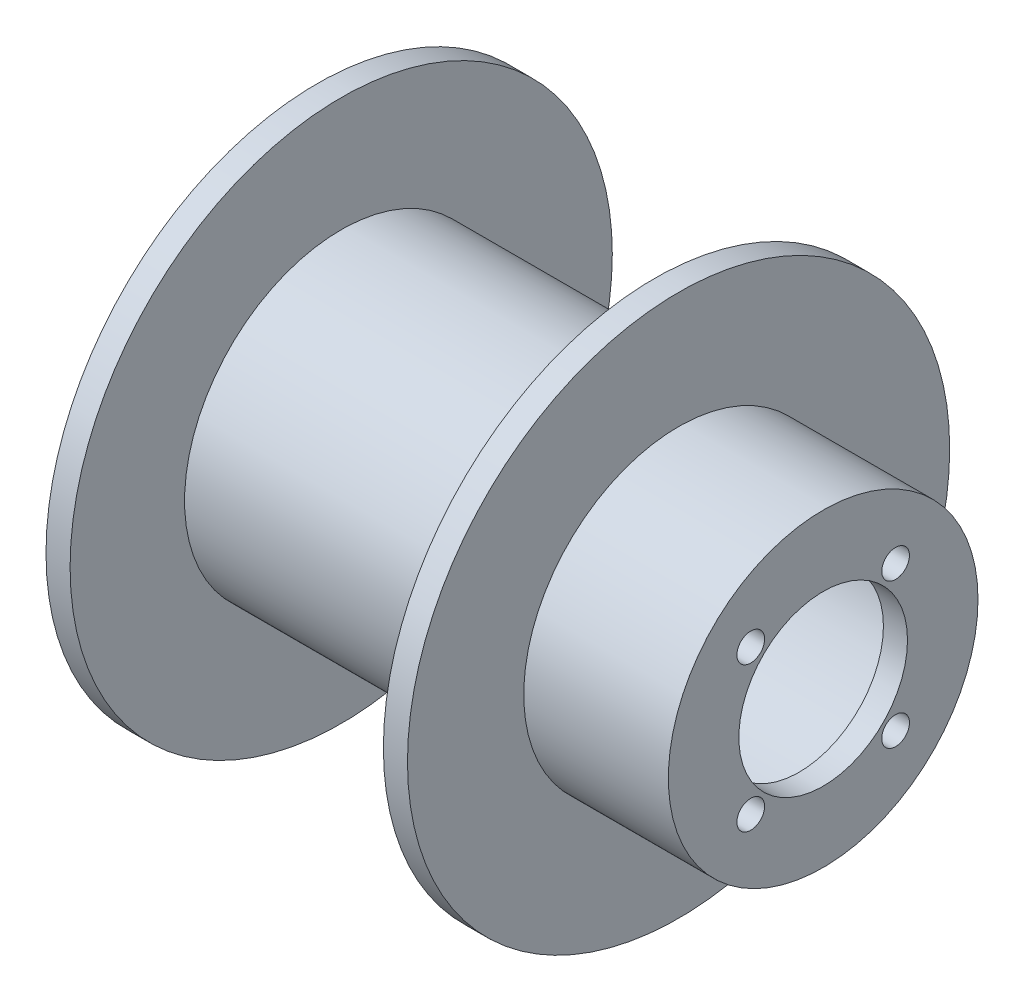
from build123d import *

# Parameters (mm, degrees)
SKETCH2_R           = 12.85
SKETCH2_R_2         = 12
BOSS_EXTRUDE2_DEPTH = 14
SKETCH3_R           = 12.85
SKETCH3_R_2         = 7
BOSS_EXTRUDE3_DEPTH = 2
BOSS_EXTRUDE5_START = -14
SKETCH4_R           = 22.5
SKETCH4_R_2         = 12
BOSS_EXTRUDE5_DEPTH = 2
BOSS_EXTRUDE6_START = -14
SKETCH6_R           = 13
SKETCH6_R_2         = 12
BOSS_EXTRUDE6_DEPTH = 26
BOSS_EXTRUDE7_START = -40
SKETCH7_R           = 22.5
SKETCH7_R_2         = 12
BOSS_EXTRUDE7_DEPTH = 2
SKETCH8_R           = 1.15
CUT_EXTRUDE1_DEPTH  = 43


with BuildPart() as part:
    # Sketch2 → Boss-Extrude2 (new body)
    with BuildSketch(Plane(origin=(0, 0, 0), x_dir=(0, 0, -1), z_dir=(1, 0, 0))):
        Circle(SKETCH2_R)
        Circle(SKETCH2_R_2, mode=Mode.SUBTRACT)
    extrude(amount=-BOSS_EXTRUDE2_DEPTH)

    # Sketch3 → Boss-Extrude3 (add)
    with BuildSketch(Plane(origin=(0, 0, 0), x_dir=(0, 0, -1), z_dir=(1, 0, 0))):
        Circle(SKETCH3_R)
        Circle(SKETCH3_R_2, mode=Mode.SUBTRACT)
    extrude(amount=-BOSS_EXTRUDE3_DEPTH)

    # Sketch4 → Boss-Extrude5 (add)
    with BuildSketch(Plane(origin=(0, 0, 0), x_dir=(0, 0, -1), z_dir=(1, 0, 0)).offset(BOSS_EXTRUDE5_START)):
        Circle(SKETCH4_R)
        Circle(SKETCH4_R_2, mode=Mode.SUBTRACT)
    extrude(amount=BOSS_EXTRUDE5_DEPTH)

    # Sketch6 → Boss-Extrude6 (add)
    with BuildSketch(Plane(origin=(0, 0, 0), x_dir=(0, 0, -1), z_dir=(1, 0, 0)).offset(BOSS_EXTRUDE6_START)):
        Circle(SKETCH6_R)
        Circle(SKETCH6_R_2, mode=Mode.SUBTRACT)
    extrude(amount=-BOSS_EXTRUDE6_DEPTH)

    # Sketch8 → Cut-Extrude1 (cut, through all)
    with BuildSketch(Plane(origin=(0, 0, 0), x_dir=(0, 0, -1), z_dir=(1, 0, 0))):
        with Locations((6.01040764, 6.01040764)):
            Circle(SKETCH8_R)
        with Locations((6.01040764, -6.01040764)):
            Circle(SKETCH8_R)
        with Locations((-6.01040764, -6.01040764)):
            Circle(SKETCH8_R)
        with Locations((-6.01040764, 6.01040764)):
            Circle(SKETCH8_R)
    extrude(amount=-CUT_EXTRUDE1_DEPTH, mode=Mode.SUBTRACT)


with BuildPart() as body_2:
    # Sketch7 → Boss-Extrude7 (new body)
    with BuildSketch(Plane(origin=(0, 0, 0), x_dir=(0, 0, -1), z_dir=(1, 0, 0)).offset(BOSS_EXTRUDE7_START)):
        Circle(SKETCH7_R)
        Circle(SKETCH7_R_2, mode=Mode.SUBTRACT)
    extrude(amount=-BOSS_EXTRUDE7_DEPTH)


solid = Compound([part.part, body_2.part])
